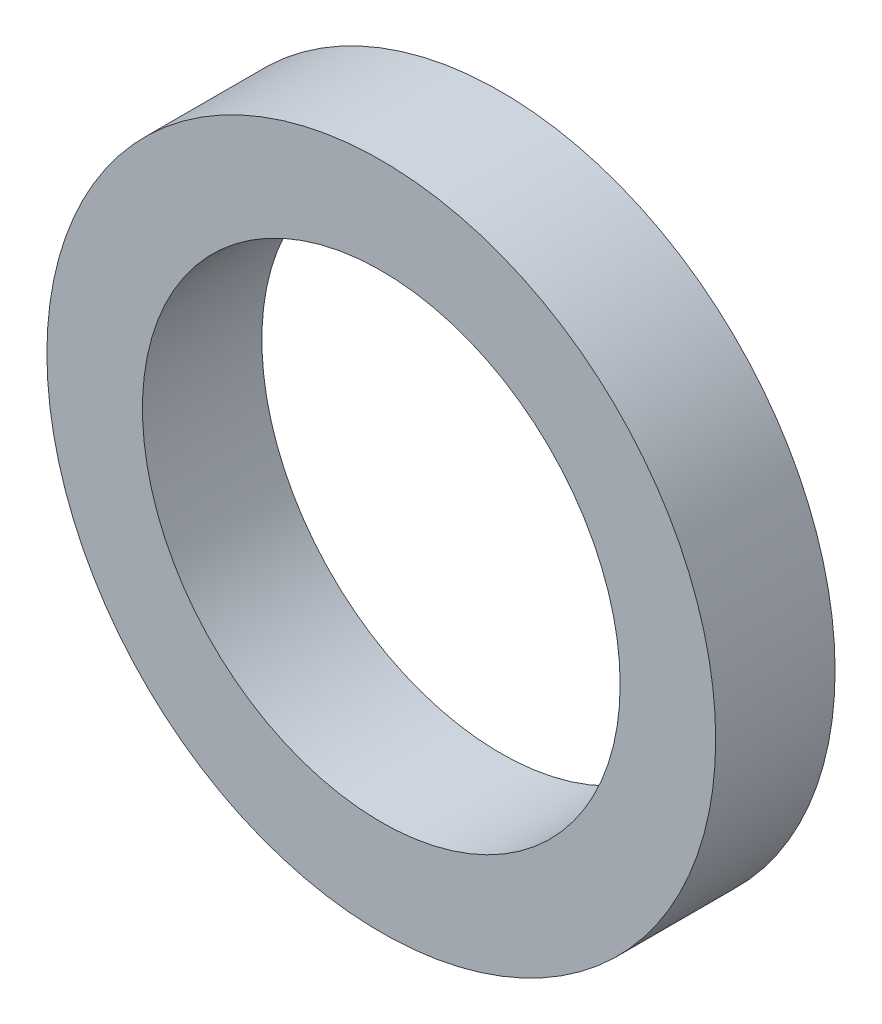
from build123d import *

# Parameters (mm, degrees)
SKETCH1_R           = 11.1125
SKETCH1_R_2         = 7.9375
BOSS_EXTRUDE1_DEPTH = 3.96748


with BuildPart() as part:
    # Sketch1 → Boss-Extrude1 (new body)
    with BuildSketch(Plane.XY):
        Circle(SKETCH1_R)
        Circle(SKETCH1_R_2, mode=Mode.SUBTRACT)
    extrude(amount=BOSS_EXTRUDE1_DEPTH)


solid = part.part
